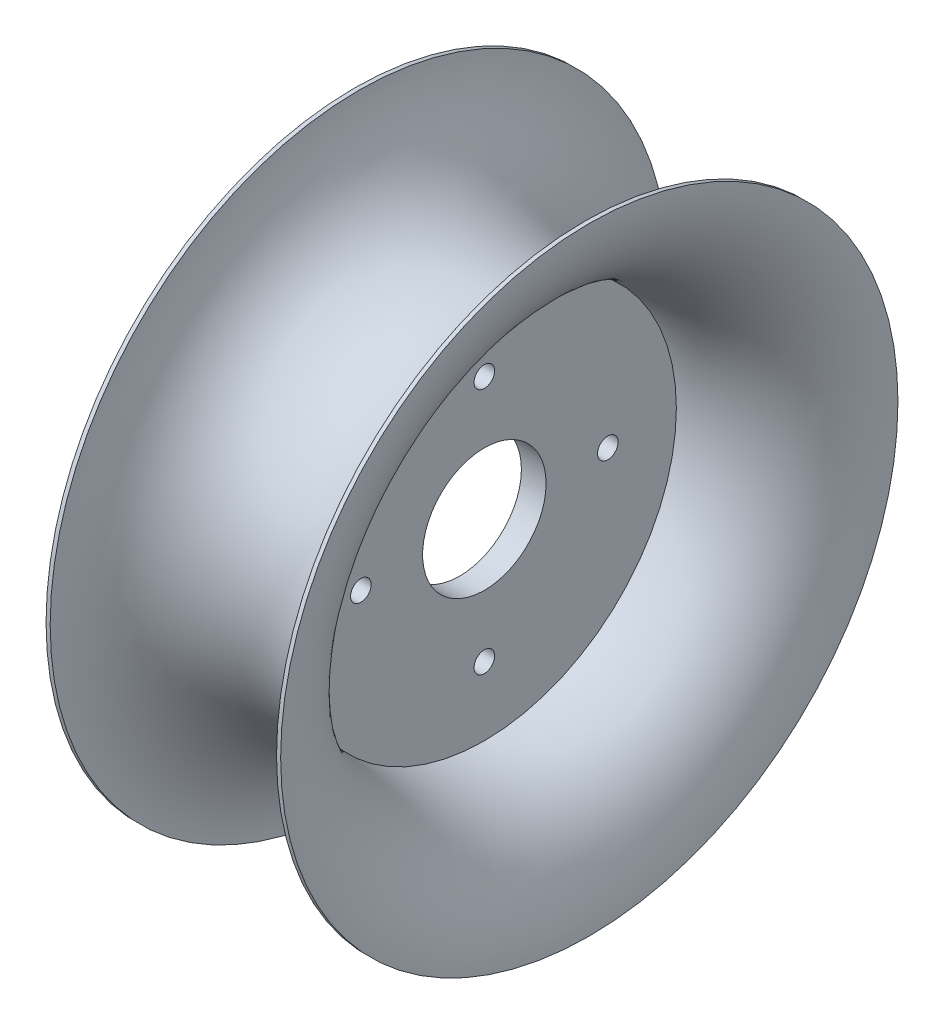
from build123d import *

# Parameters (mm, degrees)
SKETCH1_R           = 101.6
BOSS_EXTRUDE1_DEPTH = 27.5
CUT_EXTRUDE1_START  = -3
SKETCH2_R           = 60
CUT_EXTRUDE1_DEPTH  = 500
CUT_EXTRUDE2_START  = 503
SKETCH2_2_R         = 60
CUT_EXTRUDE2_DEPTH  = 500
FILLET1_R           = 15
FILLET5_R           = 6
SKETCH5_W           = 2
SKETCH5_H           = 10
CUT_EXTRUDE4_DEPTH  = 26
SKETCH6_R           = 15
CUT_EXTRUDE5_DEPTH  = 24
SKETCH7_R           = 2.5
CUT_EXTRUDE6_DEPTH  = 24
SKETCH8_R           = 127.50390304
SKETCH8_R_2         = 75
CUT_EXTRUDE7_DEPTH  = 35
SKETCH9_R           = 28.5


with BuildPart() as part:
    # Sketch1 → Boss-Extrude1 (new, symmetric)
    with BuildSketch(Plane(origin=(0, 0, 0), x_dir=(0, 0, -1), z_dir=(1, 0, 0))):
        Circle(SKETCH1_R)
    extrude(amount=BOSS_EXTRUDE1_DEPTH, both=True)

    # Sketch2 → Cut-Extrude1 (cut)
    with BuildSketch(Plane(origin=(0, 0, 0), x_dir=(0, 0, -1), z_dir=(1, 0, 0)).offset(CUT_EXTRUDE1_START)):
        Circle(SKETCH2_R)
    extrude(amount=-CUT_EXTRUDE1_DEPTH, mode=Mode.SUBTRACT)

    # Sketch2_2 → Cut-Extrude2 (cut)
    with BuildSketch(Plane(origin=(0, 0, 0), x_dir=(0, 0, -1), z_dir=(1, 0, 0)).offset(CUT_EXTRUDE2_START)):
        Circle(SKETCH2_2_R)
    extrude(amount=-CUT_EXTRUDE2_DEPTH, mode=Mode.SUBTRACT)

    # Fillet1
    fillet1_edges = [part.edges().sort_by_distance(p)[0] for p in [
        (-27.5, 0, 60),
        (27.5, 0, 60),
    ]]
    fillet(fillet1_edges, radius=FILLET1_R)

    # Fillet5
    fillet5_edges = [part.edges().sort_by_distance(p)[0] for p in [
        (27.5, 0, 101.6),
        (-27.5, 0, 101.6),
    ]]
    fillet(fillet5_edges, radius=FILLET5_R)

    # Sketch5 → Cut-Extrude4 (cut, symmetric)
    with BuildSketch(Plane(origin=(0, 0, 0), x_dir=(0, 0, -1), z_dir=(1, 0, 0))):
        Polygon((8.416153141, 104.666940178), (10.408101729, 104.487661561), (9.51170864, 94.527918621), (7.519760052, 94.707197238), align=None)
        with Locations((0, 100)):
            Rectangle(SKETCH5_W, SKETCH5_H)
        Polygon((17.764544365, 103.491163698), (19.732403542, 103.134049908), (17.946834594, 93.294754022), (15.978975417, 93.651867812), align=None)
        Polygon((26.969905924, 101.482137219), (28.897831645, 100.950063528), (26.23746319, 91.310434921), (24.309537468, 91.842508612), align=None)
        Polygon((35.958121658, 98.656036241), (37.830591399, 97.953286593), (34.316843158, 88.590937887), (32.444373417, 89.293687535), align=None)
        Polygon((44.656823739, 95.035614869), (46.458761475, 94.167847391), (42.119924084, 85.158158712), (40.317986348, 86.02592619), align=None)
        Polygon((52.995975334, 90.650022606), (54.712872921, 89.624224051), (49.583880147, 81.039736115), (47.86698256, 82.06553467), align=None)
        Polygon((60.908434496, 85.534569662), (62.526468485, 84.358999157), (56.648615962, 76.268829213), (55.030581973, 77.444399718), align=None)
        Polygon((68.330494758, 79.730442656), (69.83663769, 78.414565204), (63.25725043, 70.883850544), (61.751107498, 72.199727996), align=None)
        Polygon((75.202398053, 73.284373007), (76.584523351, 71.83878328), (69.356574713, 64.92815679), (67.974449415, 66.373746518), align=None)
        Polygon((81.468815857, 66.248260678), (82.715795461, 64.684597713), (74.897480636, 58.449699694), (73.650501033, 60.013362659), align=None)
        Polygon((87.079294659, 58.678756306), (88.181088622, 57.009609799), (79.835356085, 51.500639984), (78.733562122, 53.169786492), align=None)
        Polygon((91.988662182, 50.636805092), (92.936399507, 48.875614028), (84.130444189, 44.136927403), (83.182706864, 45.898118467), align=None)
        Polygon((96.157391086, 42.187156096), (96.94344115, 40.348100551), (87.748163424, 36.417850235), (86.962113361, 38.25690578), align=None)
        Polygon((99.551917217, 33.397840926), (100.169951205, 31.495727893), (90.659386042, 28.405557949), (90.041352054, 30.307670982), align=None)
        Polygon((102.144909845, 24.339625978), (102.589951713, 22.389770153), (92.840672591, 20.164560814), (92.395630723, 22.114416638), align=None)
        Polygon((103.91549172, 15.085442673), (104.183958251, 13.103543149), (94.274460634, 11.761210491), (94.005994102, 13.743110014), align=None)
        Polygon((104.849407157, 5.709800253), (104.939136817, 3.71181412), (94.949206152, 3.263165817), (94.859476491, 5.26115195), align=None)
        Polygon((104.939136817, -3.71181412), (104.849407157, -5.709800253), (94.859476491, -5.26115195), (94.949206152, -3.263165817), align=None)
        Polygon((104.183958251, -13.103543149), (103.91549172, -15.085442673), (94.005994102, -13.743110014), (94.274460634, -11.761210491), align=None)
        Polygon((102.589951713, -22.389770153), (102.144909845, -24.339625978), (92.395630723, -22.114416638), (92.840672591, -20.164560814), align=None)
        Polygon((100.169951205, -31.495727893), (99.551917217, -33.397840926), (90.041352054, -30.307670982), (90.659386042, -28.405557949), align=None)
        Polygon((96.94344115, -40.348100551), (96.157391086, -42.187156096), (86.962113361, -38.25690578), (87.748163424, -36.417850235), align=None)
        Polygon((92.936399507, -48.875614028), (91.988662183, -50.636805092), (83.182706864, -45.898118467), (84.130444189, -44.136927403), align=None)
        Polygon((88.181088622, -57.009609799), (87.079294659, -58.678756306), (78.733562122, -53.169786492), (79.835356085, -51.500639984), align=None)
        Polygon((82.715795461, -64.684597713), (81.468815857, -66.248260678), (73.650501033, -60.013362659), (74.897480636, -58.449699694), align=None)
        Polygon((76.584523351, -71.83878328), (75.202398053, -73.284373007), (67.974449415, -66.373746518), (69.356574713, -64.92815679), align=None)
        Polygon((69.83663769, -78.414565204), (68.330494758, -79.730442656), (61.751107498, -72.199727996), (63.25725043, -70.883850544), align=None)
        Polygon((62.526468485, -84.358999157), (60.908434496, -85.534569662), (55.030581973, -77.444399718), (56.648615962, -76.268829213), align=None)
        Polygon((54.712872921, -89.624224051), (52.995975334, -90.650022606), (47.86698256, -82.06553467), (49.583880147, -81.039736115), align=None)
        Polygon((46.458761475, -94.167847391), (44.656823739, -95.035614869), (40.317986348, -86.02592619), (42.119924084, -85.158158712), align=None)
        Polygon((37.830591399, -97.953286593), (35.958121658, -98.656036241), (32.444373417, -89.293687535), (34.316843158, -88.590937887), align=None)
        Polygon((28.897831645, -100.950063527), (26.969905924, -101.482137219), (24.309537468, -91.842508612), (26.23746319, -91.310434921), align=None)
        Polygon((19.732403542, -103.134049908), (17.764544365, -103.491163698), (15.978975417, -93.651867812), (17.946834594, -93.294754022), align=None)
        Polygon((10.408101729, -104.487661561), (8.416153141, -104.666940178), (7.519760052, -94.707197238), (9.51170864, -94.527918621), align=None)
        with Locations((0, -100)):
            Rectangle(SKETCH5_W, SKETCH5_H)
        Polygon((-8.416153141, -104.666940178), (-10.408101729, -104.487661561), (-9.51170864, -94.527918621), (-7.519760052, -94.707197238), align=None)
        Polygon((-17.764544365, -103.491163698), (-19.732403542, -103.134049908), (-17.946834594, -93.294754022), (-15.978975417, -93.651867812), align=None)
        Polygon((-26.969905924, -101.482137219), (-28.897831645, -100.950063528), (-26.23746319, -91.310434921), (-24.309537468, -91.842508612), align=None)
        Polygon((-35.958121658, -98.656036241), (-37.830591399, -97.953286593), (-34.316843158, -88.590937887), (-32.444373417, -89.293687535), align=None)
        Polygon((-44.656823739, -95.035614869), (-46.458761475, -94.167847391), (-42.119924084, -85.158158712), (-40.317986348, -86.02592619), align=None)
        Polygon((-52.995975334, -90.650022606), (-54.712872921, -89.624224051), (-49.583880147, -81.039736115), (-47.86698256, -82.06553467), align=None)
        Polygon((-60.908434496, -85.534569662), (-62.526468485, -84.358999157), (-56.648615962, -76.268829213), (-55.030581973, -77.444399718), align=None)
        Polygon((-68.330494758, -79.730442656), (-69.83663769, -78.414565204), (-63.25725043, -70.883850544), (-61.751107498, -72.199727996), align=None)
        Polygon((-75.202398053, -73.284373007), (-76.584523351, -71.83878328), (-69.356574713, -64.92815679), (-67.974449415, -66.373746518), align=None)
        Polygon((-81.468815857, -66.248260678), (-82.715795461, -64.684597713), (-74.897480636, -58.449699694), (-73.650501033, -60.013362659), align=None)
        Polygon((-87.079294659, -58.678756306), (-88.181088622, -57.009609799), (-79.835356085, -51.500639984), (-78.733562122, -53.169786492), align=None)
        Polygon((-91.988662182, -50.636805092), (-92.936399507, -48.875614028), (-84.130444189, -44.136927403), (-83.182706864, -45.898118467), align=None)
        Polygon((-96.157391086, -42.187156096), (-96.94344115, -40.348100551), (-87.748163424, -36.417850235), (-86.962113361, -38.25690578), align=None)
        Polygon((-99.551917217, -33.397840926), (-100.169951205, -31.495727893), (-90.659386042, -28.405557949), (-90.041352054, -30.307670982), align=None)
        Polygon((-102.144909845, -24.339625978), (-102.589951713, -22.389770153), (-92.840672591, -20.164560814), (-92.395630723, -22.114416638), align=None)
        Polygon((-103.91549172, -15.085442673), (-104.183958251, -13.103543149), (-94.274460634, -11.761210491), (-94.005994102, -13.743110014), align=None)
        Polygon((-104.849407156, -5.709800253), (-104.939136817, -3.71181412), (-94.949206152, -3.263165817), (-94.859476491, -5.26115195), align=None)
        Polygon((-104.939136817, 3.71181412), (-104.849407156, 5.709800253), (-94.859476491, 5.26115195), (-94.949206152, 3.263165817), align=None)
        Polygon((-104.183958251, 13.103543149), (-103.91549172, 15.085442673), (-94.005994102, 13.743110014), (-94.274460634, 11.761210491), align=None)
        Polygon((-102.589951713, 22.389770153), (-102.144909845, 24.339625978), (-92.395630723, 22.114416638), (-92.840672591, 20.164560814), align=None)
        Polygon((-100.169951205, 31.495727893), (-99.551917217, 33.397840926), (-90.041352054, 30.307670982), (-90.659386042, 28.405557949), align=None)
        Polygon((-96.94344115, 40.348100551), (-96.157391086, 42.187156096), (-86.962113361, 38.25690578), (-87.748163424, 36.417850235), align=None)
        Polygon((-92.936399507, 48.875614028), (-91.988662182, 50.636805092), (-83.182706864, 45.898118467), (-84.130444189, 44.136927403), align=None)
        Polygon((-88.181088622, 57.009609799), (-87.079294659, 58.678756306), (-78.733562122, 53.169786492), (-79.835356085, 51.500639984), align=None)
        Polygon((-82.715795461, 64.684597713), (-81.468815857, 66.248260678), (-73.650501033, 60.013362659), (-74.897480636, 58.449699694), align=None)
        Polygon((-76.584523351, 71.83878328), (-75.202398053, 73.284373007), (-67.974449415, 66.373746518), (-69.356574713, 64.92815679), align=None)
        Polygon((-69.83663769, 78.414565204), (-68.330494758, 79.730442656), (-61.751107498, 72.199727996), (-63.25725043, 70.883850544), align=None)
        Polygon((-62.526468485, 84.358999157), (-60.908434496, 85.534569662), (-55.030581973, 77.444399718), (-56.648615962, 76.268829213), align=None)
        Polygon((-54.712872921, 89.624224051), (-52.995975334, 90.650022606), (-47.86698256, 82.06553467), (-49.583880147, 81.039736115), align=None)
        Polygon((-46.458761475, 94.167847391), (-44.656823739, 95.035614869), (-40.317986348, 86.02592619), (-42.119924084, 85.158158712), align=None)
        Polygon((-37.830591399, 97.953286593), (-35.958121658, 98.656036241), (-32.444373417, 89.293687535), (-34.316843158, 88.590937887), align=None)
        Polygon((-28.897831645, 100.950063527), (-26.969905924, 101.482137219), (-24.309537468, 91.842508612), (-26.23746319, 91.310434921), align=None)
        Polygon((-19.732403542, 103.134049908), (-17.764544365, 103.491163698), (-15.978975417, 93.651867812), (-17.946834594, 93.294754022), align=None)
        Polygon((-10.408101729, 104.487661561), (-8.416153141, 104.666940178), (-7.519760052, 94.707197238), (-9.51170864, 94.527918621), align=None)
    extrude(amount=CUT_EXTRUDE4_DEPTH, both=True, mode=Mode.SUBTRACT)

    # Sketch6 → Cut-Extrude5 (cut, symmetric)
    with BuildSketch(Plane(origin=(3, 0, 0), x_dir=(0, 0, -1), z_dir=(1, 0, 0))):
        Circle(SKETCH6_R)
    extrude(amount=CUT_EXTRUDE5_DEPTH, both=True, mode=Mode.SUBTRACT)

    # Sketch7 → Cut-Extrude6 (cut, symmetric)
    with BuildSketch(Plane.ZY.offset(3)):
        with Locations((30, 0)):
            Circle(SKETCH7_R)
        with Locations((0, -30)):
            Circle(SKETCH7_R)
        with Locations((-30, 0)):
            Circle(SKETCH7_R)
        with Locations((0, 30)):
            Circle(SKETCH7_R)
    extrude(amount=CUT_EXTRUDE6_DEPTH, both=True, mode=Mode.SUBTRACT)

    # Sketch8 → Cut-Extrude7 (cut, symmetric)
    with BuildSketch(Plane(origin=(0, 0, 0), x_dir=(0, 0, -1), z_dir=(1, 0, 0))):
        Circle(SKETCH8_R)
        Circle(SKETCH8_R_2, mode=Mode.SUBTRACT)
    extrude(amount=CUT_EXTRUDE7_DEPTH, both=True, mode=Mode.SUBTRACT)

    # Sketch9 → Revolve1 (revolve)
    with BuildSketch(Plane(origin=(0, 0, 0), x_dir=(1, 0, 0), z_dir=(0, 1, 0))):
        with Locations((0, 75)):
            Circle(SKETCH9_R)
    revolve(axis=Axis((-37.662242246, 0, 0), (1, 0, 0)))

    # Sketch10 → Cut-Revolve1 (revolve, cut)
    with BuildSketch(Plane(origin=(0, 0, 0), x_dir=(1, 0, 0), z_dir=(0, 1, 0))):
        with BuildLine():
            Line((40, 109.76204441), (-40, 109.76204441))
            Line((-40, 109.76204441), (-40, 74.99795559))
            Line((-40, 74.99795559), (-27.499999924, 74.99795559))
            ThreePointArc((-27.499999924, 74.99795559), (0, 47.5), (27.499999924, 74.99795559))
            Line((27.499999924, 74.99795559), (40, 74.99795559))
            Line((40, 74.99795559), (40, 109.76204441))
        make_face()
    revolve(axis=Axis((-77.752245463, 0, 0), (1, 0, 0)), mode=Mode.SUBTRACT)


solid = part.part
